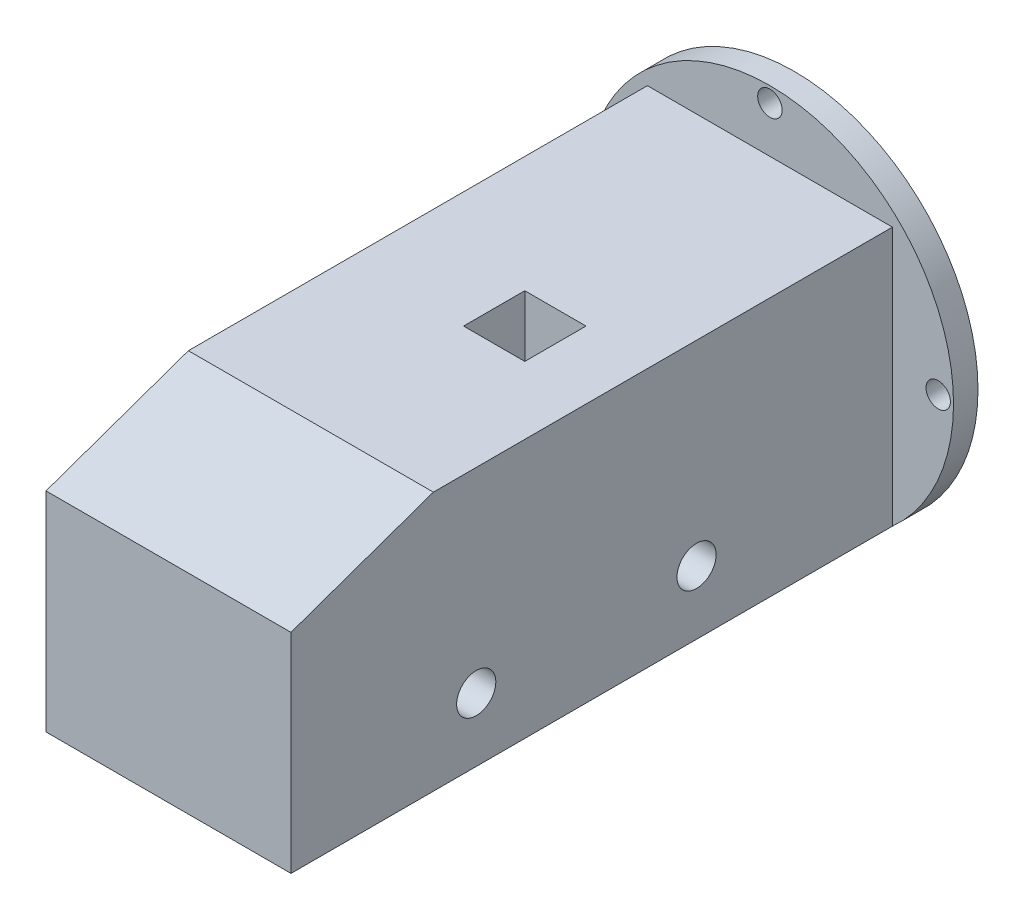
from build123d import *

# Parameters (mm, degrees)
CROQUIS1_R                 = 30
CROQUIS1_R_2               = 1.99901262
SALIENTE_EXTRUIR1_DEPTH    = 4
CROQUIS2_W                 = 40.0311451
CROQUIS2_H                 = 42.320959557
SALIENTE_EXTRUIR2_DEPTH    = 150
CORTAR_EXTRUIR1_REACH      = 166.674
CROQUIS3_R                 = 3.2
CROQUIS4_W                 = 33.4
CROQUIS4_H                 = 13
CORTAR_EXTRUIR2_DEPTH      = 12
CROQUIS5_W                 = 21.241045897
CROQUIS5_H                 = 13
CORTAR_EXTRUIR3_DEPTH      = 17
CROQUIS6_R                 = 1
CORTAR_EXTRUIR4_DEPTH      = 5
CORTAR_EXTRUIR6_DEPTH      = 165.674094798
CORTAR_EXTRUIR6_DEPTH_BACK = 165.674094798
CROQUIS10_R                = 3.2
CORTAR_EXTRUIR10_DEPTH     = 10
CROQUIS11_W                = 14
CROQUIS11_H                = 13
CORTAR_EXTRUIR11_DEPTH     = 6.1
CROQUIS12_W                = 10
CROQUIS12_H                = 9.978436174
CORTAR_EXTRUIR12_DEPTH     = 17
CROQUIS13_W                = 10
CROQUIS13_H                = 10
CORTAR_EXTRUIR13_DEPTH     = 45
CROQUIS11_3_W              = 14
CROQUIS11_3_H              = 13
CORTAR_EXTRUIR18_DEPTH     = 27.3


with BuildPart() as part:
    # Croquis1 → Saliente-Extruir1 (new body)
    with BuildSketch(Plane.XY):
        Circle(CROQUIS1_R)
        with Locations((27.5, 0)):
            Circle(CROQUIS1_R_2, mode=Mode.SUBTRACT)
        with Locations((0, -27.5)):
            Circle(CROQUIS1_R_2, mode=Mode.SUBTRACT)
        with Locations((-27.5, 0)):
            Circle(CROQUIS1_R_2, mode=Mode.SUBTRACT)
        with Locations((0, 27.5)):
            Circle(CROQUIS1_R_2, mode=Mode.SUBTRACT)
    extrude(amount=SALIENTE_EXTRUIR1_DEPTH)

    # Croquis2 → Saliente-Extruir2 (add)
    with BuildSketch(Plane.XY.offset(4)):
        with Locations((0, -1.186261717)):
            Rectangle(CROQUIS2_W, CROQUIS2_H)
    extrude(amount=SALIENTE_EXTRUIR2_DEPTH)

    # Croquis3 → Cortar-Extruir1 (cut, up to next)
    with BuildSketch(Plane.ZY.offset(20.01557255), mode=Mode.PRIVATE) as cortar_extruir1_sk1:
        with Locations((36, -11.961033968)):
            Circle(CROQUIS3_R)
    cortar_extruir1_tool1 = extrude(cortar_extruir1_sk1.sketch, amount=-CORTAR_EXTRUIR1_REACH, mode=Mode.PRIVATE) & part.part
    add(cortar_extruir1_tool1.solids().sort_by_distance((-20.015573, -11.961034, 36))[0], mode=Mode.SUBTRACT)

    # Croquis4 → Cortar-Extruir2 (cut)
    with BuildSketch(Plane.ZY.offset(20.01557255)):
        with Locations((76.773642677, -11.961033968)):
            Rectangle(CROQUIS4_W, CROQUIS4_H)
    extrude(amount=-CORTAR_EXTRUIR2_DEPTH, mode=Mode.SUBTRACT)

    # Croquis5 → Cortar-Extruir3 (cut)
    with BuildSketch(Plane.ZY.offset(8.01557255)):
        with Locations((76.753119728, -11.961033968)):
            Rectangle(CROQUIS5_W, CROQUIS5_H)
    extrude(amount=-CORTAR_EXTRUIR3_DEPTH, mode=Mode.SUBTRACT)

    # Croquis6 → Cortar-Extruir4 (cut)
    with BuildSketch(Plane.ZY.offset(8.01557255)):
        with Locations((63.103119729, -11.961033968)):
            Circle(CROQUIS6_R)
        with Locations((90.423642677, -11.961033968)):
            Circle(CROQUIS6_R)
    extrude(amount=-CORTAR_EXTRUIR4_DEPTH, mode=Mode.SUBTRACT)

    # Croquis7 → Cortar-Extruir6 (cut, two sides: drawn at the far end of the back side and taken through both)
    with BuildSketch(Plane.ZY.offset(20.01557255).offset(-CORTAR_EXTRUIR6_DEPTH_BACK)):
        Polygon((102.262078688, -22.346741496), (154, -22.346741496), (154, 19.974218061), (79, 19.974218061), (102.262078688, 11.767260679), align=None)
    extrude(amount=CORTAR_EXTRUIR6_DEPTH + CORTAR_EXTRUIR6_DEPTH_BACK, mode=Mode.SUBTRACT)

    # Croquis10 → Cortar-Extruir10 (cut)
    with BuildSketch(Plane(origin=(20.01557255, 0, 0), x_dir=(0, 0, -1), z_dir=(1, 0, 0))):
        with Locations((-72, -11.961033968)):
            Circle(CROQUIS10_R)
    extrude(amount=-CORTAR_EXTRUIR10_DEPTH, mode=Mode.SUBTRACT)

    # Croquis11 → Cortar-Extruir11 (cut)
    with BuildSketch(Plane.XY.offset(66.13259678)):
        with Locations((1.98442745, -11.961033968)):
            Rectangle(CROQUIS11_W, CROQUIS11_H)
    extrude(amount=-CORTAR_EXTRUIR11_DEPTH, mode=Mode.SUBTRACT)

    # Croquis12 → Cortar-Extruir12 (cut)
    with BuildSketch(Plane.XY.offset(60.03259678)):
        with Locations((3.98442745, -11.950252055)):
            Rectangle(CROQUIS12_W, CROQUIS12_H)
    extrude(amount=-CORTAR_EXTRUIR12_DEPTH, mode=Mode.SUBTRACT)

    # Croquis13 → Cortar-Extruir13 (cut)
    with BuildSketch(Plane.XZ.offset(6.961033968)):
        with Locations((3.98442745, 48.03259678)):
            Rectangle(CROQUIS13_W, CROQUIS13_H)
    extrude(amount=-CORTAR_EXTRUIR13_DEPTH, mode=Mode.SUBTRACT)

    # Croquis11_3 → Cortar-Extruir18 (cut)
    with BuildSketch(Plane.XY.offset(66.13259678)):
        with Locations((1.98442745, -11.961033968)):
            Rectangle(CROQUIS11_3_W, CROQUIS11_3_H)
    extrude(amount=CORTAR_EXTRUIR18_DEPTH, mode=Mode.SUBTRACT)


solid = part.part
